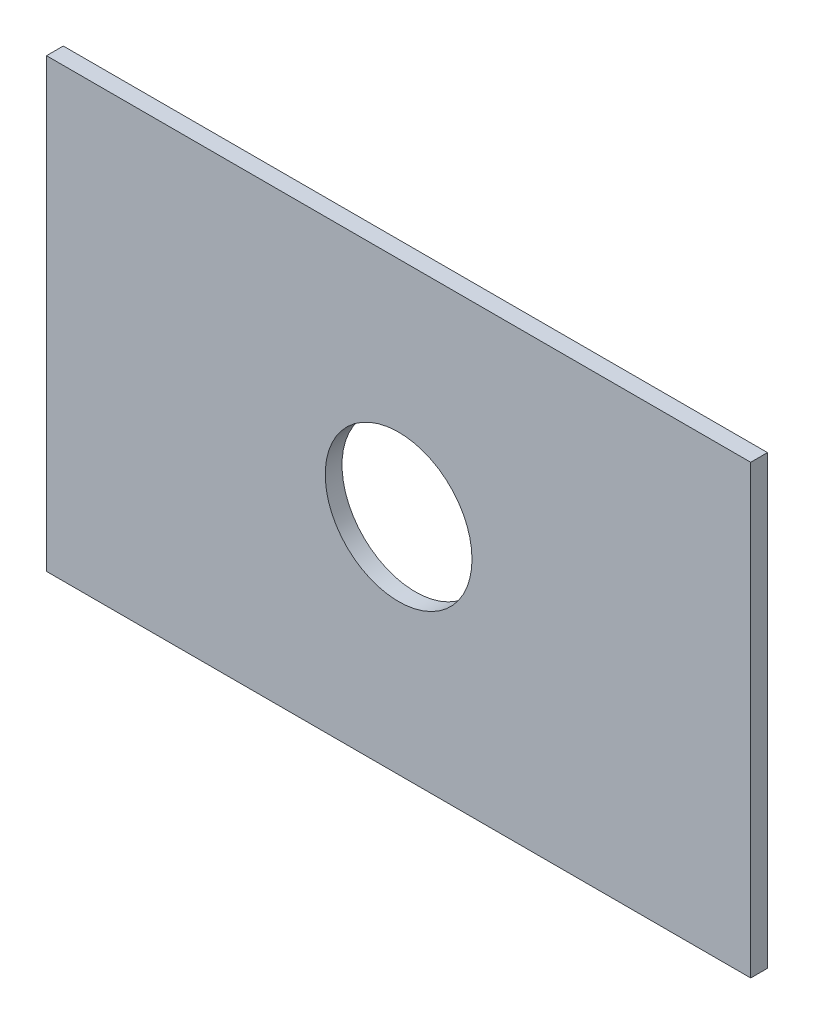
from build123d import *

# Parameters (mm, degrees)
SKETCH1_W           = 106.627222576
SKETCH1_H           = 67.626243964
SKETCH1_R           = 11.1125
BOSS_EXTRUDE1_DEPTH = 2.54


with BuildPart() as part:
    # Sketch1 → Boss-Extrude1 (new body)
    with BuildSketch(Plane.XY):
        Rectangle(SKETCH1_W, SKETCH1_H)
        Circle(SKETCH1_R, mode=Mode.SUBTRACT)
    extrude(amount=BOSS_EXTRUDE1_DEPTH)


solid = part.part
